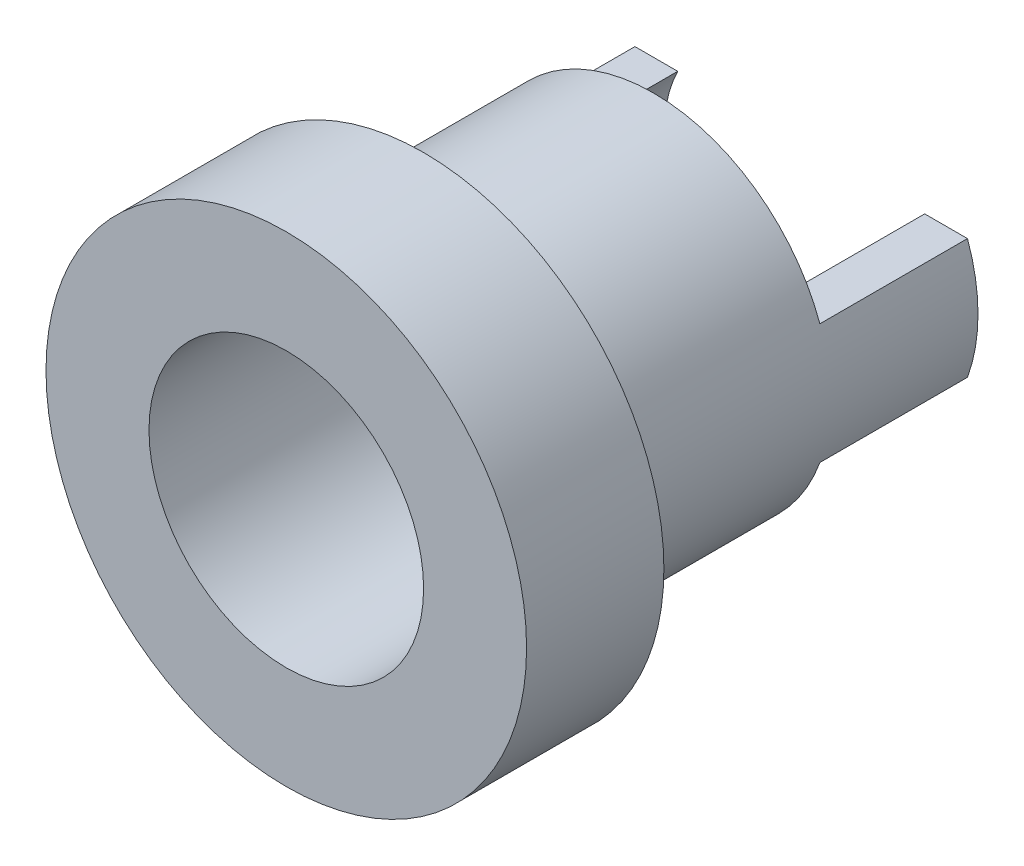
from build123d import *

# Parameters (mm, degrees)
SKETCH_1_R               = 7
EXTRUDE_1_DEPTH          = 4
SKETCH_2_R               = 5.15
EXTRUDE_2_DEPTH          = 11
SKETCH_3_R               = 4
CUT_EXTRUDE_1_DEPTH      = 1
CUT_EXTRUDE_1_DEPTH_BACK = 16
SKETCH_6_W               = 4.3
SKETCH_6_H               = 3.4
CUT_EXTRUDE_2_DEPTH      = 8
CUT_EXTRUDE_2_DEPTH_BACK = 8


with BuildPart() as part:
    # 草图1 → 凸台-拉伸1 (new body)
    with BuildSketch(Plane.XY):
        Circle(SKETCH_1_R)
    extrude(amount=EXTRUDE_1_DEPTH)

    # 草图2 → 凸台-拉伸2 (add)
    with BuildSketch(Plane(origin=(0, 0, 0), x_dir=(-1, 0, 0), z_dir=(0, 0, -1))):
        Circle(SKETCH_2_R)
    extrude(amount=EXTRUDE_2_DEPTH)

    # 草图3 → 切除-拉伸1 (cut, two sides)
    with BuildSketch(Plane(origin=(0, 0, -11), x_dir=(-1, 0, 0), z_dir=(0, 0, -1))) as cut_extrude_1_sk:
        Circle(SKETCH_3_R)
    extrude(amount=CUT_EXTRUDE_1_DEPTH, mode=Mode.SUBTRACT)
    extrude(cut_extrude_1_sk.sketch, amount=-CUT_EXTRUDE_1_DEPTH_BACK, mode=Mode.SUBTRACT)

    # 草图6 → 切除-拉伸2 (cut, two sides)
    with BuildSketch(Plane(origin=(0, 0, 0), x_dir=(0, 0, -1), z_dir=(1, 0, 0))) as cut_extrude_2_sk:
        with Locations((8.85, 3.45)):
            Rectangle(SKETCH_6_W, SKETCH_6_H)
        with Locations((8.85, -3.45)):
            Rectangle(SKETCH_6_W, SKETCH_6_H)
    extrude(amount=CUT_EXTRUDE_2_DEPTH, mode=Mode.SUBTRACT)
    extrude(cut_extrude_2_sk.sketch, amount=-CUT_EXTRUDE_2_DEPTH_BACK, mode=Mode.SUBTRACT)


solid = part.part
